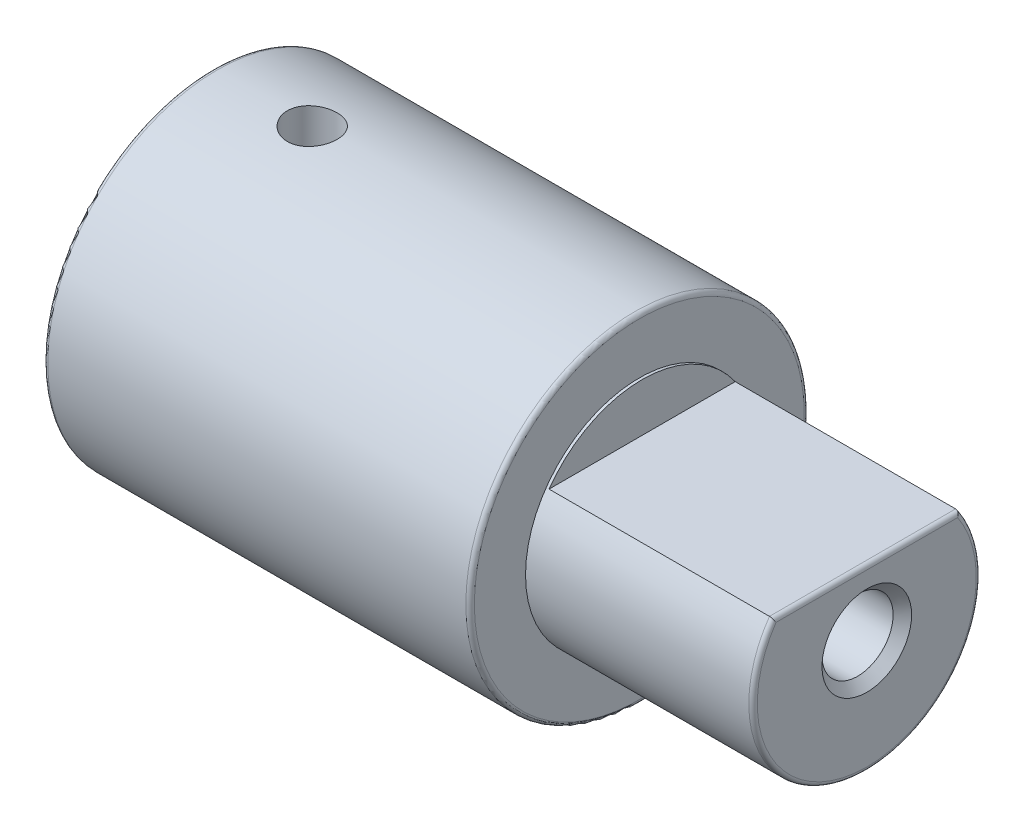
from build123d import *

# Parameters (mm, degrees)
CUT_EXTRUDE1_DEPTH          = 7.9
M3_TAPPED_HOLE1_D           = 2.5
M3_TAPPED_HOLE1_CSINK_D     = 3.15
M3_TAPPED_HOLE1_CSINK_ANGLE = 90
FILLET1_R                   = 0.15
SKETCH6_R                   = 0.875
CUT_EXTRUDE2_DEPTH          = 6


with BuildPart() as part:
    # Sketch2 → Revolve1 (revolve)
    with BuildSketch(Plane(origin=(0, 0, 0), x_dir=(1, 0, 0), z_dir=(0, 1, 0))):
        Polygon((0, 2.5), (13.1, 2.5), (13.1, 0), (23, 0), (23, 4), (15, 4), (15, 5.95), (0, 5.95), align=None)
    revolve(axis=Axis((0, 0, 0), (1, 0, 0)))

    # Sketch3 → Cut-Extrude1 (cut)
    with BuildSketch(Plane(origin=(23, 0, 0), x_dir=(0, 0, -1), z_dir=(1, 0, 0))):
        with BuildLine():
            Line((-3.272613634, 2.3), (3.272613634, 2.3))
            ThreePointArc((3.272613634, 2.3), (0, 4), (-3.272613634, 2.3))
        make_face()
    extrude(amount=-CUT_EXTRUDE1_DEPTH, mode=Mode.SUBTRACT)

    # M3 Tapped Hole1 (through all)
    with Locations(Plane(origin=(23, 0, 0), x_dir=(0, 0, 1), z_dir=(1, 0, 0))):
        with Locations((0, 0)):
            CounterSinkHole(M3_TAPPED_HOLE1_D / 2, M3_TAPPED_HOLE1_CSINK_D / 2, counter_sink_angle=M3_TAPPED_HOLE1_CSINK_ANGLE)

    # Fillet1
    fillet1_edges = [part.edges().sort_by_distance(p)[0] for p in [
        (23, -3.813820561, 1.206139599),
        (23, 2.3, 0),
        (0, 0, 2.5),
        (0, 0, 5.95),
        (15, 0, 5.95),
    ]]
    fillet(fillet1_edges, radius=FILLET1_R)

    # Sketch6 → Cut-Extrude2 (cut)
    with BuildSketch(Plane(origin=(0, 5.95, 0), x_dir=(1, 0, 0), z_dir=(0, 1, 0))):
        with Locations((3.5, 0)):
            Circle(SKETCH6_R)
    extrude(amount=-CUT_EXTRUDE2_DEPTH, mode=Mode.SUBTRACT)


solid = part.part
